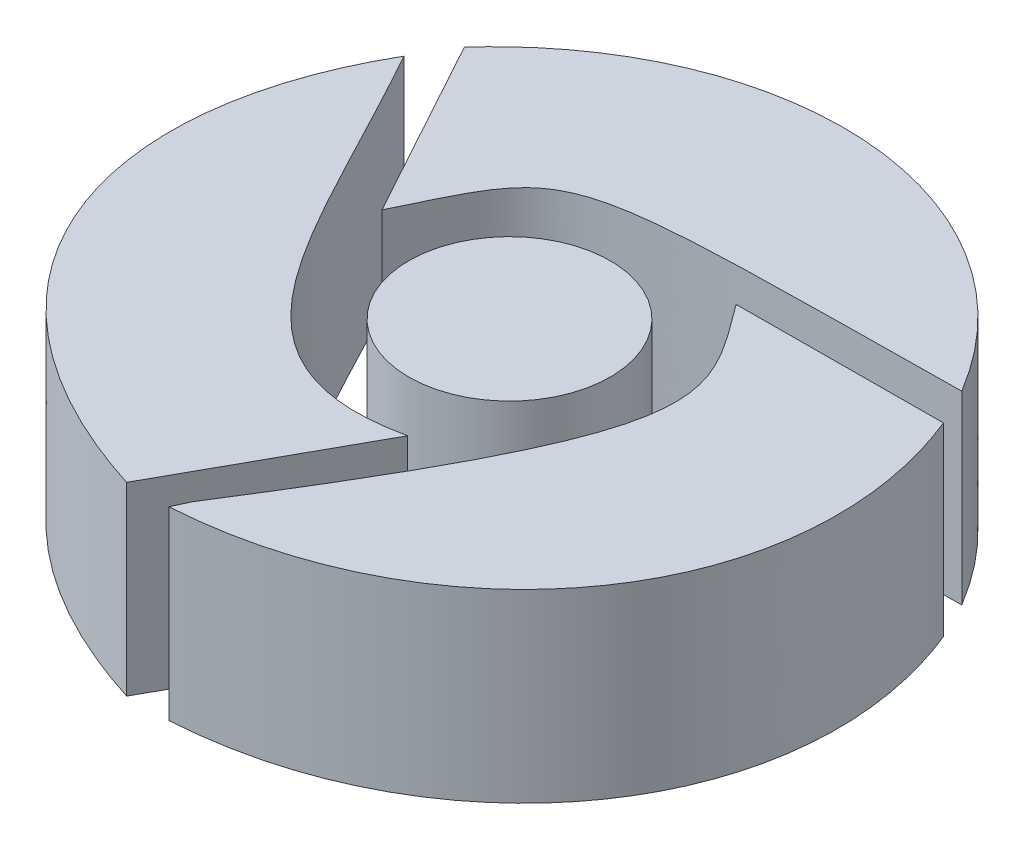
from build123d import *

# Parameters (mm, degrees)
SKETCH1_R             = 1.088272776
BOSS_EXTRUDE1_DEPTH   = 2
BOSS_EXTRUDE1_2_DEPTH = 2
BOSS_EXTRUDE1_3_DEPTH = 2
BOSS_EXTRUDE1_4_DEPTH = 2


with BuildPart() as part:
    # Sketch1 → Boss-Extrude1 (new body)
    with BuildSketch(Plane(origin=(0, 0, 0), x_dir=(1, 0, 0), z_dir=(0, 1, 0))):
        with Locations((4.493692826, 4.377208968)):
            Circle(SKETCH1_R)
    extrude(amount=BOSS_EXTRUDE1_DEPTH)


with BuildPart() as body_2:
    # Sketch1 → Boss-Extrude1 2 (new body)
    with BuildSketch(Plane(origin=(0, 0, 0), x_dir=(1, 0, 0), z_dir=(0, 1, 0))):
        with BuildLine():
            add(Edge.make_bspline(
                [(1.708302736, 6.675020322), (2.7850769, 4.708112849)],
                knots=[0, 0, 1, 1], degree=1))
            add(Edge.make_bspline(
                [(2.7850769, 4.708112849), (3.503027953, 6.18454421), (3.250577965, 6.087201429), (7.612209781, 6.143754191)],
                knots=[0, 0, 0, 0, 1, 1, 1, 1], degree=3))
            add(Edge.make_bspline(
                [(7.612209781, 6.143754191), (6.254944774, 8.405862536), (3.390492052, 8.548738808), (1.708302736, 6.675020322)],
                knots=[0, 0, 0, 0, 1, 1, 1, 1], degree=3))
        make_face()
    extrude(amount=BOSS_EXTRUDE1_2_DEPTH)


with BuildPart() as body_3:
    # Sketch1 → Boss-Extrude1 3 (new body)
    with BuildSketch(Plane(origin=(0, 0, 0), x_dir=(1, 0, 0), z_dir=(0, 1, 0))):
        with BuildLine():
            add(Edge.make_bspline(
                [(5.581965603, 5.736574301), (7.81014445, 5.747884853)],
                knots=[0, 0, 1, 1], degree=1))
            add(Edge.make_bspline(
                [(7.81014445, 5.747884853), (8.793174762, 3.315863121), (7.166280408, 0.951883368), (4.411440439, 0.780285592)],
                knots=[0, 0, 0, 0, 1, 1, 1, 1], degree=3))
            add(Edge.make_bspline(
                [(4.493692826, 0.957799974), (4.411440439, 0.780285592)],
                knots=[0, 0, 1, 1], degree=1))
            add(Edge.make_bspline(
                [(5.581965603, 5.736574301), (6.355689478, 4.69227355), (6.68715092, 4.422069049), (4.493692826, 0.957799974)],
                knots=[0, 0, 0, 0, 1, 1, 1, 1], degree=3))
        make_face()
    extrude(amount=BOSS_EXTRUDE1_3_DEPTH)


with BuildPart() as body_4:
    # Sketch1 → Boss-Extrude1 4 (new body)
    with BuildSketch(Plane(origin=(0, 0, 0), x_dir=(1, 0, 0), z_dir=(0, 1, 0))):
        with BuildLine():
            add(Edge.make_bspline(
                [(1.465683791, 6.263578757), (2.685567613, 4.097099076), (3.184226619, 2.333384223), (5.036898253, 2.733412737)],
                knots=[0, 0, 0, 0, 1, 1, 1, 1], degree=3))
            add(Edge.make_bspline(
                [(3.954884534, 0.780285592), (5.036898253, 2.733412737)],
                knots=[0, 0, 1, 1], degree=1))
            add(Edge.make_bspline(
                [(1.465683791, 6.263578757), (0.260024603, 4.182083143), (0.973294196, 1.73068737), (3.954884534, 0.780285592)],
                knots=[0, 0, 0, 0, 1, 1, 1, 1], degree=3))
        make_face()
    extrude(amount=BOSS_EXTRUDE1_4_DEPTH)


solid = Compound([part.part, body_2.part, body_3.part, body_4.part])
